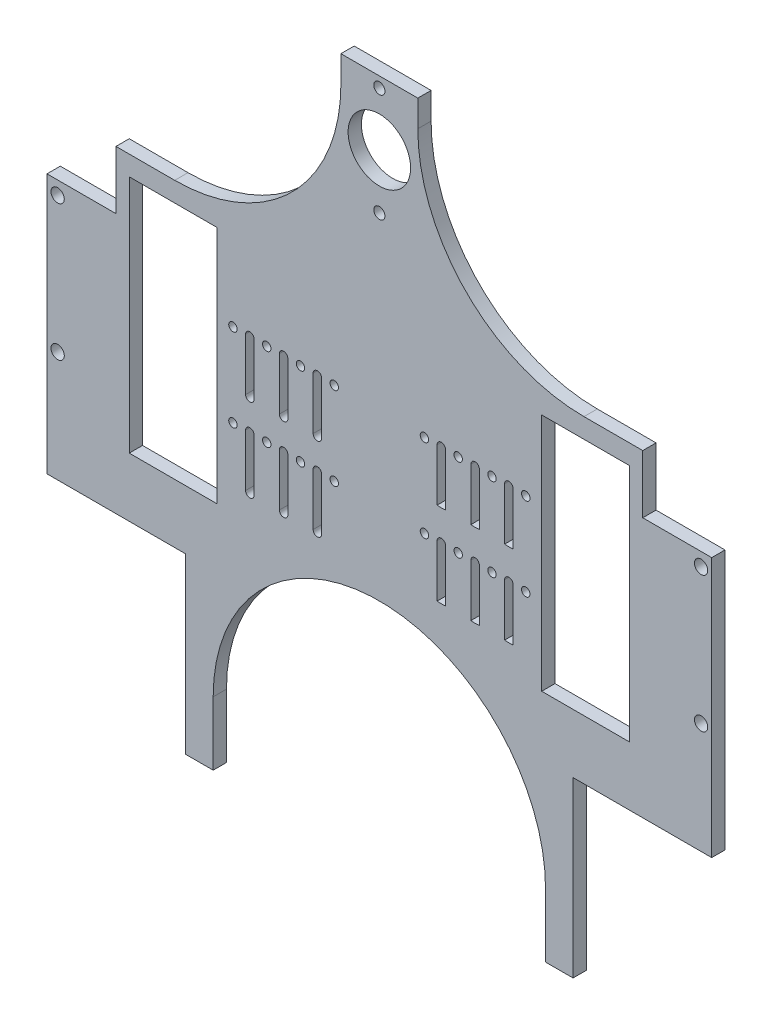
from build123d import *

# Parameters (mm, degrees)
SKETCH1_W           = 250
SKETCH1_H           = 340.4
SKETCH1_R           = 2.1
SKETCH1_R_2         = 2.5
SKETCH1_R_3         = 1.59
SKETCH1_R_4         = 11.75
SKETCH1_W_2         = 33
SKETCH1_H_2         = 90
BOSS_EXTRUDE1_DEPTH = 5
SKETCH12_W          = 250
SKETCH12_H          = 5
CUT_EXTRUDE2_DEPTH  = 83
CUT_EXTRUDE3_DEPTH  = 6
SKETCH15_W          = 30.082256647
SKETCH15_H          = 10
SKETCH15_W_2        = 26.03414052
CUT_EXTRUDE4_DEPTH  = 10
SKETCH17_W          = 52.148371748
SKETCH17_H          = 66.780027045
CUT_EXTRUDE5_DEPTH  = 10


with BuildPart() as part:
    # Sketch1 → Boss-Extrude1 (new body)
    with BuildSketch(Plane.XY):
        with Locations((125, -170.2)):
            Rectangle(SKETCH1_W, SKETCH1_H)
        with Locations((125, -44.64)):
            Circle(SKETCH1_R, mode=Mode.SUBTRACT)
        with Locations((125, -4)):
            Circle(SKETCH1_R, mode=Mode.SUBTRACT)
        with Locations((246, -99.4)):
            Circle(SKETCH1_R_2, mode=Mode.SUBTRACT)
        with Locations((246, -150.4)):
            Circle(SKETCH1_R_2, mode=Mode.SUBTRACT)
        with Locations((180.06, -109.275)):
            Circle(SKETCH1_R_3, mode=Mode.SUBTRACT)
        with Locations((180.06, -140.525)):
            Circle(SKETCH1_R_3, mode=Mode.SUBTRACT)
        with Locations((125, -24.14)):
            Circle(SKETCH1_R_4, mode=Mode.SUBTRACT)
        with Locations((141.96, -109.275)):
            Circle(SKETCH1_R_3, mode=Mode.SUBTRACT)
        with Locations((154.66, -109.275)):
            Circle(SKETCH1_R_3, mode=Mode.SUBTRACT)
        with Locations((167.36, -109.275)):
            Circle(SKETCH1_R_3, mode=Mode.SUBTRACT)
        with Locations((141.96, -140.525)):
            Circle(SKETCH1_R_3, mode=Mode.SUBTRACT)
        with Locations((154.66, -140.525)):
            Circle(SKETCH1_R_3, mode=Mode.SUBTRACT)
        with Locations((167.36, -140.525)):
            Circle(SKETCH1_R_3, mode=Mode.SUBTRACT)
        with Locations((82.64, -140.525)):
            Circle(SKETCH1_R_3, mode=Mode.SUBTRACT)
        with Locations((95.34, -140.525)):
            Circle(SKETCH1_R_3, mode=Mode.SUBTRACT)
        with Locations((108.04, -140.525)):
            Circle(SKETCH1_R_3, mode=Mode.SUBTRACT)
        with Locations((82.64, -109.275)):
            Circle(SKETCH1_R_3, mode=Mode.SUBTRACT)
        with Locations((95.34, -109.275)):
            Circle(SKETCH1_R_3, mode=Mode.SUBTRACT)
        with Locations((108.04, -109.275)):
            Circle(SKETCH1_R_3, mode=Mode.SUBTRACT)
        with Locations((69.94, -140.525)):
            Circle(SKETCH1_R_3, mode=Mode.SUBTRACT)
        with Locations((69.94, -109.275)):
            Circle(SKETCH1_R_3, mode=Mode.SUBTRACT)
        with Locations((4, -150.4)):
            Circle(SKETCH1_R_2, mode=Mode.SUBTRACT)
        with Locations((4, -99.4)):
            Circle(SKETCH1_R_2, mode=Mode.SUBTRACT)
        with Locations((202.56, -124.9)):
            Rectangle(SKETCH1_W_2, SKETCH1_H_2, mode=Mode.SUBTRACT)
        with BuildLine():
            Line((146.7225, -109.275), (146.7225, -128.954634918))
            ThreePointArc((146.7225, -128.954634918), (148.31, -129.040223925), (149.8975, -128.954634918))
            Line((149.8975, -128.954634918), (149.8975, -109.275))
            ThreePointArc((149.8975, -109.275), (148.31, -107.6875), (146.7225, -109.275))
        make_face(mode=Mode.SUBTRACT)
        with BuildLine():
            Line((159.42, -109.275), (159.42, -128.954634918))
            ThreePointArc((159.42, -128.954634918), (161.01, -129.040492925), (162.6, -128.954634918))
            Line((162.6, -128.954634918), (162.6, -109.275))
            ThreePointArc((162.6, -109.275), (161.01, -107.685), (159.42, -109.275))
        make_face(mode=Mode.SUBTRACT)
        with BuildLine():
            Line((172.12, -109.275), (172.12, -128.954634918))
            ThreePointArc((172.12, -128.954634918), (173.71, -129.040492925), (175.3, -128.954634918))
            Line((175.3, -128.954634918), (175.3, -109.275))
            ThreePointArc((175.3, -109.275), (173.71, -107.685), (172.12, -109.275))
        make_face(mode=Mode.SUBTRACT)
        with BuildLine():
            Line((146.7225, -140.525), (146.7225, -160.204634918))
            ThreePointArc((146.7225, -160.204634918), (148.31, -160.290223925), (149.8975, -160.204634918))
            Line((149.8975, -160.204634918), (149.8975, -140.525))
            ThreePointArc((149.8975, -140.525), (148.31, -138.9375), (146.7225, -140.525))
        make_face(mode=Mode.SUBTRACT)
        with BuildLine():
            Line((159.42, -140.525), (159.42, -160.204634918))
            ThreePointArc((159.42, -160.204634918), (161.01, -160.290492925), (162.6, -160.204634918))
            Line((162.6, -160.204634918), (162.6, -140.525))
            ThreePointArc((162.6, -140.525), (161.01, -138.935), (159.42, -140.525))
        make_face(mode=Mode.SUBTRACT)
        with BuildLine():
            Line((172.12, -140.525), (172.12, -160.204634918))
            ThreePointArc((172.12, -160.204634918), (173.71, -160.290492925), (175.3, -160.204634918))
            Line((175.3, -160.204634918), (175.3, -140.525))
            ThreePointArc((175.3, -140.525), (173.71, -138.935), (172.12, -140.525))
        make_face(mode=Mode.SUBTRACT)
        with BuildLine():
            Line((103.2775, -109.275), (103.2775, -128.954634918))
            ThreePointArc((103.2775, -128.954634918), (101.69, -130.542134918), (100.1025, -128.954634918))
            Line((100.1025, -128.954634918), (100.1025, -109.275))
            ThreePointArc((100.1025, -109.275), (101.69, -107.6875), (103.2775, -109.275))
        make_face(mode=Mode.SUBTRACT)
        with BuildLine():
            Line((90.58, -109.275), (90.58, -128.954634918))
            ThreePointArc((90.58, -128.954634918), (88.99, -130.544634918), (87.4, -128.954634918))
            Line((87.4, -128.954634918), (87.4, -109.275))
            ThreePointArc((87.4, -109.275), (88.99, -107.685), (90.58, -109.275))
        make_face(mode=Mode.SUBTRACT)
        with BuildLine():
            Line((77.88, -109.275), (77.88, -128.954634918))
            ThreePointArc((77.88, -128.954634918), (76.29, -130.544634918), (74.7, -128.954634918))
            Line((74.7, -128.954634918), (74.7, -109.275))
            ThreePointArc((74.7, -109.275), (76.29, -107.685), (77.88, -109.275))
        make_face(mode=Mode.SUBTRACT)
        with BuildLine():
            Line((103.2775, -140.525), (103.2775, -160.204634918))
            ThreePointArc((103.2775, -160.204634918), (101.69, -161.792134918), (100.1025, -160.204634918))
            Line((100.1025, -160.204634918), (100.1025, -140.525))
            ThreePointArc((100.1025, -140.525), (101.69, -138.9375), (103.2775, -140.525))
        make_face(mode=Mode.SUBTRACT)
        with BuildLine():
            Line((90.58, -140.525), (90.58, -160.204634918))
            ThreePointArc((90.58, -160.204634918), (88.99, -161.794634918), (87.4, -160.204634918))
            Line((87.4, -160.204634918), (87.4, -140.525))
            ThreePointArc((87.4, -140.525), (88.99, -138.935), (90.58, -140.525))
        make_face(mode=Mode.SUBTRACT)
        with BuildLine():
            Line((77.88, -140.525), (77.88, -160.204634918))
            ThreePointArc((77.88, -160.204634918), (76.29, -161.794634918), (74.7, -160.204634918))
            Line((74.7, -160.204634918), (74.7, -140.525))
            ThreePointArc((74.7, -140.525), (76.29, -138.935), (77.88, -140.525))
        make_face(mode=Mode.SUBTRACT)
        with Locations((47.44, -124.9)):
            Rectangle(SKETCH1_W_2, SKETCH1_H_2, mode=Mode.SUBTRACT)
    extrude(amount=BOSS_EXTRUDE1_DEPTH)

    # Sketch12 → Cut-Extrude2 (cut)
    with BuildSketch(Plane.XZ.offset(340.4)):
        with Locations((125, 2.5)):
            Rectangle(SKETCH12_W, SKETCH12_H)
    extrude(amount=-CUT_EXTRUDE2_DEPTH, mode=Mode.SUBTRACT)

    # Sketch13 → Cut-Extrude3 (cut, through all)
    with BuildSketch(Plane.XY.offset(5)):
        with BuildLine():
            Line((48.038172449, -72.5), (25.94, -72.5))
            Line((25.94, -72.5), (25.94, -94.4))
            Line((25.94, -94.4), (0, -94.4))
            Line((0, -94.4), (0, 0))
            Line((0, 0), (109.732985845, 0))
            ThreePointArc((109.732985845, 0), (95.636754361, -50.504629365), (48.038172449, -72.5))
        make_face()
        with BuildLine():
            Line((250, 0), (250, -94.4))
            Line((250, -94.4), (224.06, -94.4))
            Line((224.06, -94.4), (224.06, -72.5))
            Line((224.06, -72.5), (201.961827551, -72.5))
            ThreePointArc((201.961827551, -72.5), (154.363245639, -50.504629365), (140.267014155, 0))
            Line((140.267014155, 0), (250, 0))
        make_face()
        with BuildLine():
            Line((62.5, -233.498107088), (62.5, -350.4))
            Line((62.5, -350.4), (187.5, -350.4))
            Line((187.5, -350.4), (187.5, -233.498107088))
            ThreePointArc((187.5, -233.498107088), (125, -170.998107088), (62.5, -233.498107088))
        make_face()
    extrude(amount=-CUT_EXTRUDE3_DEPTH, mode=Mode.SUBTRACT)

    # Sketch15 → Cut-Extrude4 (cut)
    with BuildSketch(Plane.XY.offset(5)):
        with Locations((95.497044125, -5)):
            Rectangle(SKETCH15_W, SKETCH15_H)
        with Locations((152.478897811, -5)):
            Rectangle(SKETCH15_W_2, SKETCH15_H)
    extrude(amount=-CUT_EXTRUDE4_DEPTH, mode=Mode.SUBTRACT)

    # Sketch17 → Cut-Extrude5 (cut)
    with BuildSketch(Plane.XY.offset(5)):
        with Locations((223.925814126, -225.511530956)):
            Rectangle(SKETCH17_W, SKETCH17_H)
        with Locations((26.074185874, -225.511530956)):
            Rectangle(SKETCH17_W, SKETCH17_H)
    extrude(amount=-CUT_EXTRUDE5_DEPTH, mode=Mode.SUBTRACT)


solid = part.part
